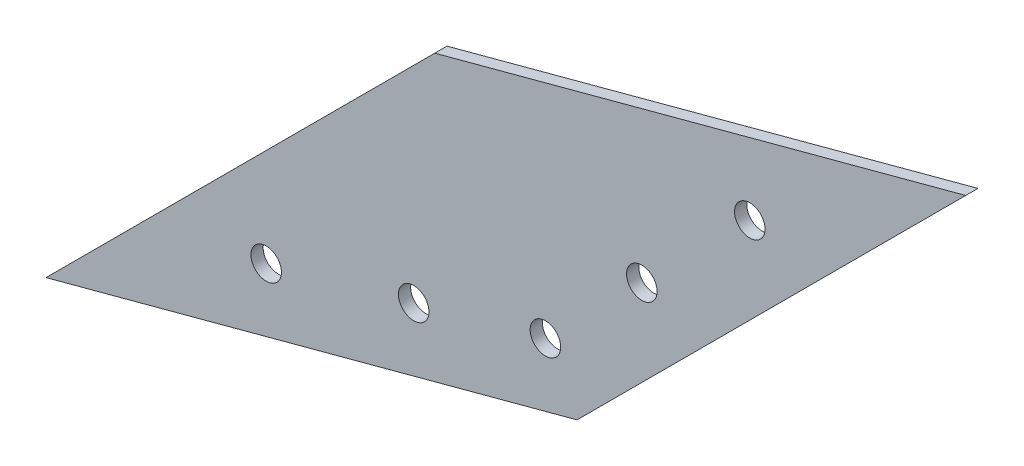
from build123d import *

# Parameters (mm, degrees)
BOSS_EXTRUDE2_DEPTH = 2
SKETCH7_R           = 2.5
CUT_EXTRUDE6_DEPTH  = 2
SKETCH8_R           = 2.5
CUT_EXTRUDE7_DEPTH  = 2
SKETCH9_R           = 2.5
CUT_EXTRUDE8_DEPTH  = 2
SKETCH10_R          = 2.5
CUT_EXTRUDE9_DEPTH  = 2
CUT_EXTRUDE10_DEPTH = 2


with BuildPart() as part:
    # Sketch1 → Boss-Extrude2 (new body)
    with BuildSketch(Plane.XY):
        Polygon((0, 0), (63.639610307, 63.639610307), (150.572934673, 86.933324366), (86.933324366, 23.293714059), align=None)
    extrude(amount=BOSS_EXTRUDE2_DEPTH)

    # Sketch7 → Cut-Extrude6 (cut)
    with BuildSketch(Plane.XY.offset(2)):
        with Locations((115.217595613, 65.72012093)):
            Circle(SKETCH7_R)
    extrude(amount=-CUT_EXTRUDE6_DEPTH, mode=Mode.SUBTRACT)

    # Sketch8 → Cut-Extrude7 (cut)
    with BuildSketch(Plane.XY.offset(2)):
        with Locations((97.539926084, 48.042451401)):
            Circle(SKETCH8_R)
    extrude(amount=-CUT_EXTRUDE7_DEPTH, mode=Mode.SUBTRACT)

    # Sketch9 → Cut-Extrude8 (cut)
    with BuildSketch(Plane.XY.offset(2)):
        with Locations((60.196988258, 26.482496195)):
            Circle(SKETCH9_R)
    extrude(amount=-CUT_EXTRUDE8_DEPTH, mode=Mode.SUBTRACT)

    # Sketch10 → Cut-Extrude9 (cut)
    with BuildSketch(Plane.XY.offset(2)):
        with Locations((36.048842601, 20.012020067)):
            Circle(SKETCH10_R)
    extrude(amount=-CUT_EXTRUDE9_DEPTH, mode=Mode.SUBTRACT)

    # Sketch11 → Cut-Extrude10 (cut)
    with BuildSketch(Plane.XY.offset(2)):
        with BuildLine():
            Line((81.756943464, 32.259468781), (80.506943464, 34.42453229))
            ThreePointArc((80.506943464, 34.42453229), (79.591879955, 31.009468781), (83.006943464, 30.094405271))
            Line((83.006943464, 30.094405271), (81.756943464, 32.259468781))
        make_face()
        with BuildLine():
            ThreePointArc((84.256943464, 32.259468781), (84.066642295, 33.216177362), (83.524710417, 34.027235734))
            Line((83.524710417, 34.027235734), (81.756943464, 32.259468781))
            Line((81.756943464, 32.259468781), (83.006943464, 30.094405271))
            ThreePointArc((83.006943464, 30.094405271), (83.922006973, 31.009468781), (84.256943464, 32.259468781))
        make_face()
        with BuildLine():
            Line((81.756943464, 32.259468781), (83.524710417, 34.027235734))
            ThreePointArc((83.524710417, 34.027235734), (82.083258945, 34.738080934), (80.506943464, 34.42453229))
            Line((80.506943464, 34.42453229), (81.756943464, 32.259468781))
        make_face()
    extrude(amount=-CUT_EXTRUDE10_DEPTH, mode=Mode.SUBTRACT)


solid = part.part
